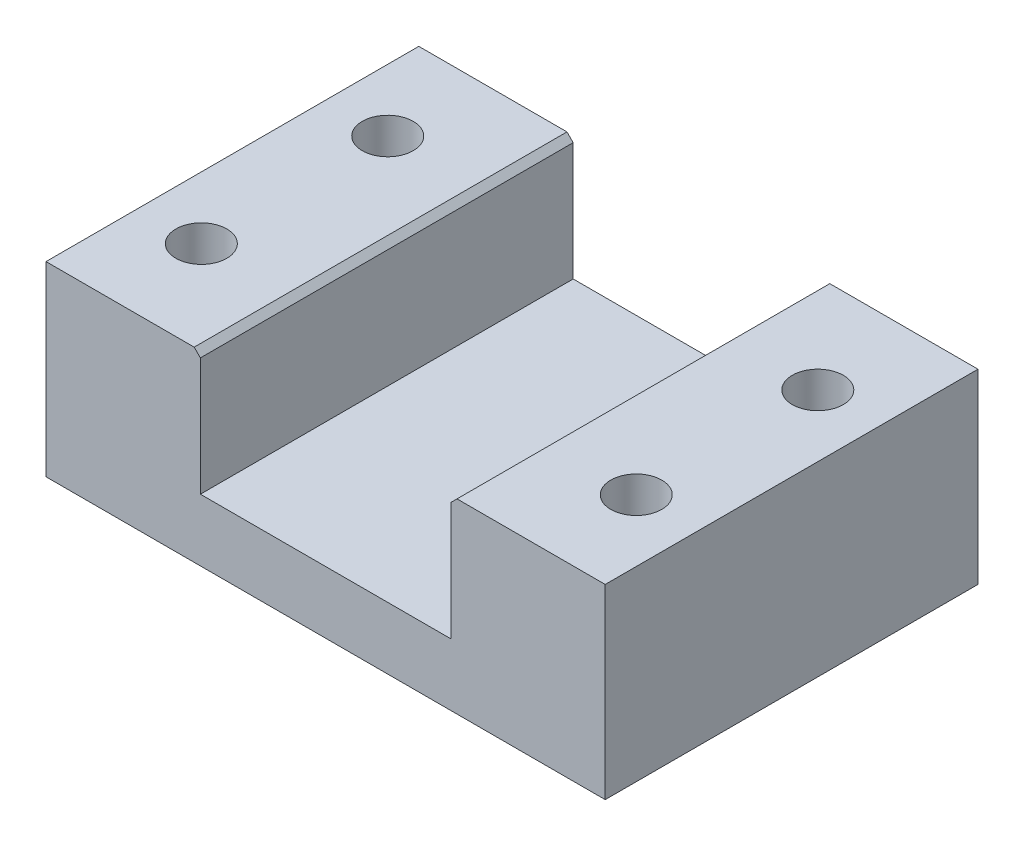
from build123d import *

# Parameters (mm, degrees)
SKETCH1_W           = 90
SKETCH1_H           = 60
BOSS_EXTRUDE1_DEPTH = 30
SKETCH2_W           = 40.3
SKETCH2_H           = 40
CUT_EXTRUDE1_DEPTH  = 61
SKETCH3_R           = 4.1
CUT_EXTRUDE2_DEPTH  = 31
SKETCH4_R           = 8.8
CUT_EXTRUDE3_DEPTH  = 10
CHAMFER1_SIZE       = 1


with BuildPart() as part:
    # Sketch1 → Boss-Extrude1 (new body)
    with BuildSketch(Plane(origin=(0, 0, 0), x_dir=(1, 0, 0), z_dir=(0, 1, 0))):
        Rectangle(SKETCH1_W, SKETCH1_H)
    extrude(amount=BOSS_EXTRUDE1_DEPTH)

    # Sketch2 → Cut-Extrude1 (cut, through all)
    with BuildSketch(Plane.XY.offset(30)):
        with Locations((0, 30)):
            Rectangle(SKETCH2_W, SKETCH2_H)
    extrude(amount=-CUT_EXTRUDE1_DEPTH, mode=Mode.SUBTRACT)

    # Sketch3 → Cut-Extrude2 (cut, through all)
    with BuildSketch(Plane.XZ):
        with Locations((-35, 15)):
            Circle(SKETCH3_R)
        with Locations((-35, -15)):
            Circle(SKETCH3_R)
        with Locations((35, -14.217273236)):
            Circle(SKETCH3_R)
        with Locations((35, 15)):
            Circle(SKETCH3_R)
    extrude(amount=-CUT_EXTRUDE2_DEPTH, mode=Mode.SUBTRACT)

    # Sketch4 → Cut-Extrude3 (cut)
    with BuildSketch(Plane.XZ):
        with Locations((35, 15)):
            Circle(SKETCH4_R)
        with Locations((35, -14.217273236)):
            Circle(SKETCH4_R)
        with Locations((-35, 15)):
            Circle(SKETCH4_R)
        with Locations((-35, -15)):
            Circle(SKETCH4_R)
    extrude(amount=-CUT_EXTRUDE3_DEPTH, mode=Mode.SUBTRACT)

    # Chamfer1
    chamfer1_edges = [part.edges().sort_by_distance(p)[0] for p in [
        (20.15, 30, 0),
        (-20.15, 30, 0),
    ]]
    chamfer(chamfer1_edges, length=CHAMFER1_SIZE)


solid = part.part
